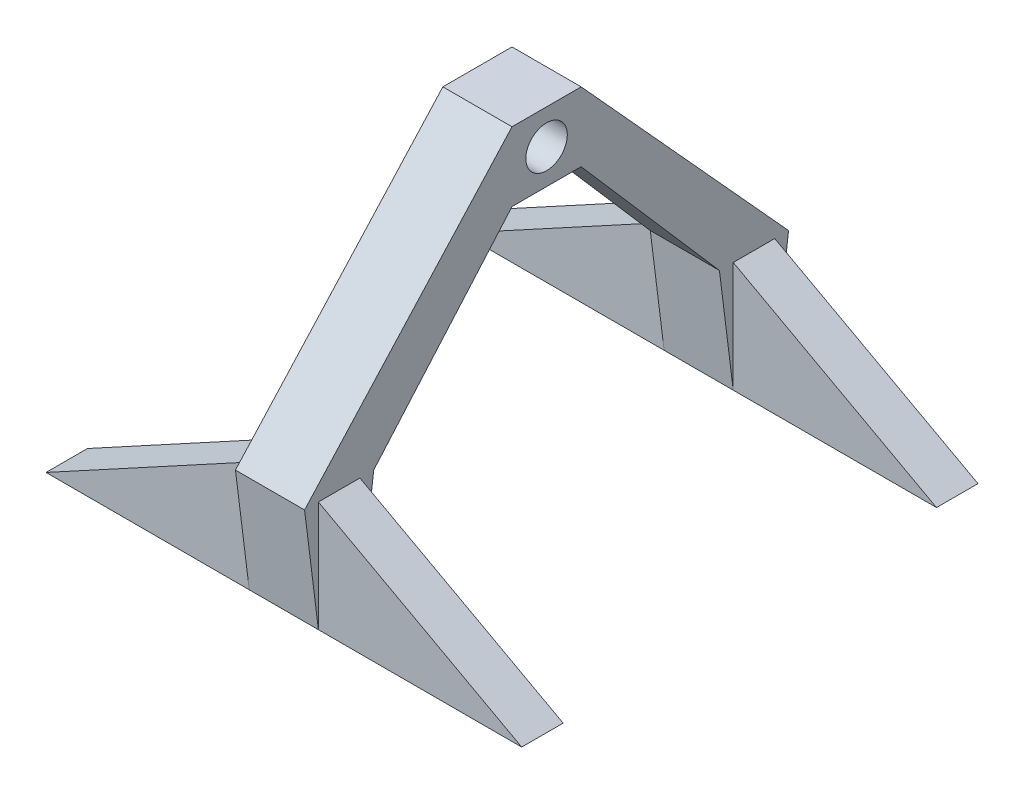
from build123d import *

# Parameters (mm, degrees)
SKETCH2_W                = 25
SKETCH2_H                = 5
SKETCH2_H_2              = 15
SKETCH2_W_2              = 73.5
BOSS_EXTRUDE3_DEPTH      = 40
CUT_EXTRUDE1_DEPTH       = 15
CUT_EXTRUDE3_DEPTH       = 25
SKETCH5_W                = 25
SKETCH5_H                = 25
SKETCH5_R                = 7.5
BOSS_EXTRUDE4_DEPTH      = 12.5
BOSS_EXTRUDE4_DEPTH_BACK = 12.5
BOSS_EXTRUDE5_START      = -12.5
BOSS_EXTRUDE5_DEPTH      = 25


with BuildPart() as part:
    # Sketch2 → Boss-Extrude3 (new body)
    with BuildSketch(Plane(origin=(0, 0, 0), x_dir=(1, 0, 0), z_dir=(0, 1, 0))):
        with Locations((0, -10)):
            Rectangle(SKETCH2_W, SKETCH2_H)
        Rectangle(SKETCH2_W, SKETCH2_H_2)
        with Locations((0, 10)):
            Rectangle(SKETCH2_W, SKETCH2_H)
        with Locations((-49.25, 0)):
            Rectangle(SKETCH2_W_2, SKETCH2_H_2)
        with Locations((49.25, 0)):
            Rectangle(SKETCH2_W_2, SKETCH2_H_2)
    extrude(amount=BOSS_EXTRUDE3_DEPTH)

    # Sketch6 → Cut-Extrude1 (cut)
    with BuildSketch(Plane(origin=(0, 0, -7.5), x_dir=(-1, 0, 0), z_dir=(0, 0, -1))):
        Polygon((12.5, 40), (86, 0), (86, 40), align=None)
    cut_extrude1 = extrude(amount=-CUT_EXTRUDE1_DEPTH, mode=Mode.SUBTRACT)

    # Mirror1: Cut-Extrude1 across plane
    add(cut_extrude1.mirror(Plane(origin=(0, 0, 0), x_dir=(0, 0, 1), z_dir=(1, 0, 0))), mode=Mode.SUBTRACT)

    # Sketch7 → Cut-Extrude3 (cut)
    with BuildSketch(Plane.ZY.offset(12.5)):
        Polygon((-12.5, 40), (-7.5, 0), (-12.5, 0), align=None)
    cut_extrude3 = extrude(amount=-CUT_EXTRUDE3_DEPTH, mode=Mode.SUBTRACT)

    # Mirror2: Cut-Extrude3 across plane
    add(cut_extrude3.mirror(Plane.XY), mode=Mode.SUBTRACT)



with BuildPart() as body_2:
    # Sketch5 → Boss-Extrude4 (new body, two sides)
    with BuildSketch(Plane(origin=(0, 0, 0), x_dir=(0, 0, -1), z_dir=(1, 0, 0))) as boss_extrude4_sk:
        with Locations((-75, 110)):
            Rectangle(SKETCH5_W, SKETCH5_H)
        with Locations((-75, 110)):
            Circle(SKETCH5_R, mode=Mode.SUBTRACT)
    extrude(amount=BOSS_EXTRUDE4_DEPTH)
    extrude(boss_extrude4_sk.sketch, amount=-BOSS_EXTRUDE4_DEPTH_BACK)


with BuildPart() as part_1:
    add(part.part)

    add(body_2.part)  # Boss-Extrude5 merges body 2
    # Sketch8 → Boss-Extrude5 (add)
    with BuildSketch(Plane(origin=(0, 0, 0), x_dir=(0, 0, -1), z_dir=(1, 0, 0)).offset(BOSS_EXTRUDE5_START)):
        Polygon((-62.5, 97.5), (-12.5, 40), (12.5, 40), (-62.5, 122.5), align=None)
    extrude(amount=BOSS_EXTRUDE5_DEPTH)

    # Mirror13: part across plane


with BuildPart() as part_2:
    add(part_1.part)
    add(part_1.part.mirror(Plane.XY.offset(75)))


solid = part_2.part
